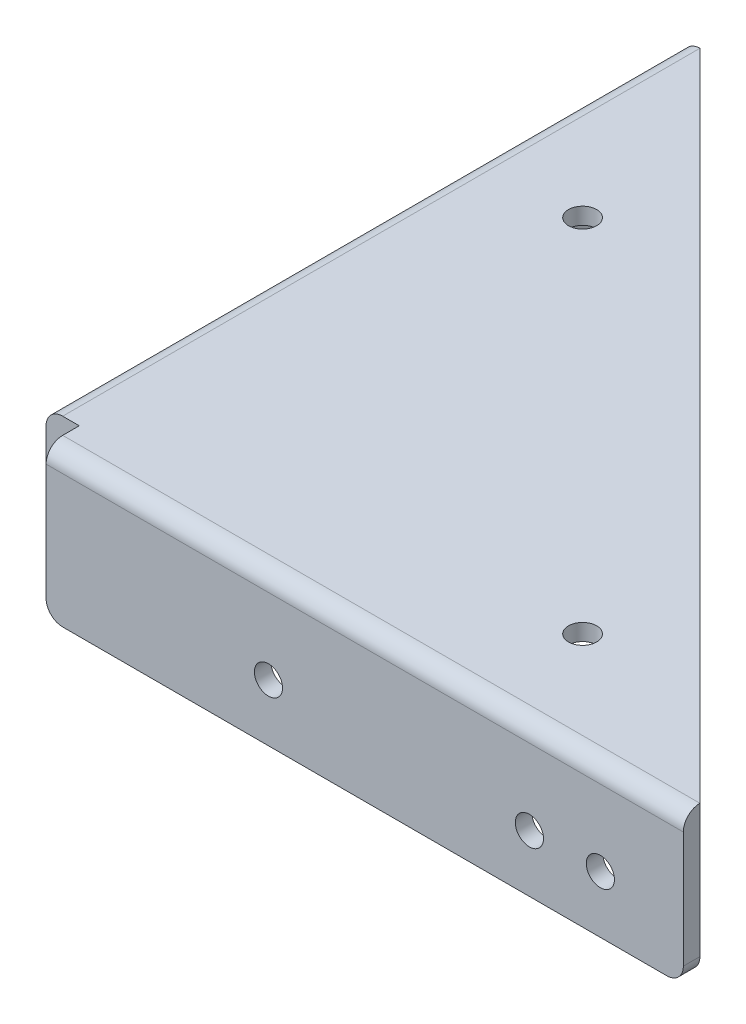
from build123d import *

# Parameters (mm, degrees)
BOSS_EXTRUDE3_DEPTH       = 22.86
BOSS_EXTRUDE4_DEPTH       = 2.54
FILLET1_R                 = 2.54
SKETCH4_W                 = 8.004359919
SKETCH4_H                 = 7.259840527
CUT_EXTRUDE1_DEPTH        = 32.004
CUT_EXTRUDE1_DEPTH_BACK   = 2.54
F_8_CLEARANCE_HOLE1_D     = 4.3053
F_8_CLEARANCE_HOLE1_DEPTH = 74.422
F_8_CLEARANCE_HOLE1_TIP   = 1.293442612
F_8_CLEARANCE_HOLE2_D     = 4.3053
F_8_CLEARANCE_HOLE2_DEPTH = 74.422
F_8_CLEARANCE_HOLE2_TIP   = 1.293442612
F_8_CLEARANCE_HOLE3_D     = 4.3053
F_8_CLEARANCE_HOLE3_DEPTH = 74.422
F_8_CLEARANCE_HOLE3_TIP   = 1.293442612
FILLET2_R                 = 2.54
SKETCH11_R                = 2.159
CUT_EXTRUDE2_DEPTH        = 7.62
SKETCH12_R                = 2.159
CUT_EXTRUDE3_DEPTH        = 7.62


with BuildPart() as part:
    # Sketch1 → Boss-Extrude3 (new body)
    with BuildSketch(Plane(origin=(0, 0, 0), x_dir=(1, 0, 0), z_dir=(0, 1, 0))):
        Polygon((102.616, 2.54), (102.616, 0), (0, 0), (0, 102.616), (2.54, 102.616), (2.54, 2.54), align=None)
    extrude(amount=BOSS_EXTRUDE3_DEPTH)

    # Sketch3 → Boss-Extrude4 (add)
    with BuildSketch(Plane(origin=(0, 22.86, 0), x_dir=(1, 0, 0), z_dir=(0, 1, 0))):
        Polygon((2.54, 102.616), (102.616, 2.54), (2.54, 2.54), align=None)
    extrude(amount=-BOSS_EXTRUDE4_DEPTH)

    # Fillet1
    fillet1_edges = [part.edges().sort_by_distance(p)[0] for p in [
        (0, 22.86, -51.308),
        (51.308, 22.86, 0),
        (2.54, 10.16, -2.54),
        (52.578, 20.32, -2.54),
        (2.54, 20.32, -52.578),
    ]]
    fillet(fillet1_edges, radius=FILLET1_R)

    # Sketch4 → Cut-Extrude1 (cut, two sides)
    with BuildSketch(Plane.XZ.offset(-20.32)) as cut_extrude1_sk:
        with Locations((1.077820041, -1.450079736)):
            Rectangle(SKETCH4_W, SKETCH4_H)
    extrude(amount=CUT_EXTRUDE1_DEPTH, mode=Mode.SUBTRACT)
    extrude(cut_extrude1_sk.sketch, amount=-CUT_EXTRUDE1_DEPTH_BACK, mode=Mode.SUBTRACT)

    # #8 Clearance Hole1
    with Locations(Plane(origin=(2.54, 0, 0), x_dir=(0, 0, -1), z_dir=(1, 0, 0))):
        with Locations((39.116, 8.73125), (89.916, 8.73125)):
            Hole(F_8_CLEARANCE_HOLE1_D / 2, depth=F_8_CLEARANCE_HOLE1_DEPTH)
            with Locations((0, 0, -(F_8_CLEARANCE_HOLE1_DEPTH + F_8_CLEARANCE_HOLE1_TIP / 2))):  # 118° drill point
                Cone(0, F_8_CLEARANCE_HOLE1_D / 2, F_8_CLEARANCE_HOLE1_TIP, mode=Mode.SUBTRACT)

    # #8 Clearance Hole2
    with Locations(Plane.XY):
        with Locations((89.916, 8.73125), (39.116, 8.73125)):
            Hole(F_8_CLEARANCE_HOLE2_D / 2, depth=F_8_CLEARANCE_HOLE2_DEPTH)
            with Locations((0, 0, -(F_8_CLEARANCE_HOLE2_DEPTH + F_8_CLEARANCE_HOLE2_TIP / 2))):  # 118° drill point
                Cone(0, F_8_CLEARANCE_HOLE2_D / 2, F_8_CLEARANCE_HOLE2_TIP, mode=Mode.SUBTRACT)

    # #8 Clearance Hole3
    with Locations(Plane(origin=(0, 20.32, 0), x_dir=(-1, 0, 0), z_dir=(0, -1, 0))):
        with Locations((-16.010384182, 71.185103576), (-71.185103576, 16.010384182)):
            Hole(F_8_CLEARANCE_HOLE3_D / 2, depth=F_8_CLEARANCE_HOLE3_DEPTH)
            with Locations((0, 0, -(F_8_CLEARANCE_HOLE3_DEPTH + F_8_CLEARANCE_HOLE3_TIP / 2))):  # 118° drill point
                Cone(0, F_8_CLEARANCE_HOLE3_D / 2, F_8_CLEARANCE_HOLE3_TIP, mode=Mode.SUBTRACT)

    # Fillet2
    fillet2_edges = [part.edges().sort_by_distance(p)[0] for p in [
        (1.27, 0, -5.08),
        (5.08, 0, -1.27),
        (1.27, 0, -102.616),
        (102.616, 0, -1.27),
    ]]
    fillet(fillet2_edges, radius=FILLET2_R)

    # Sketch11 → Cut-Extrude2 (cut)
    with BuildSketch(Plane(origin=(2.54, 0, 0), x_dir=(0, 0, -1), z_dir=(1, 0, 0))):
        with Locations((79.0575, 8.73125)):
            Circle(SKETCH11_R)
    extrude(amount=-CUT_EXTRUDE2_DEPTH, mode=Mode.SUBTRACT)

    # Sketch12 → Cut-Extrude3 (cut)
    with BuildSketch(Plane.XY):
        with Locations((79.0575, 8.73125)):
            Circle(SKETCH12_R)
    extrude(amount=-CUT_EXTRUDE3_DEPTH, mode=Mode.SUBTRACT)


solid = part.part
